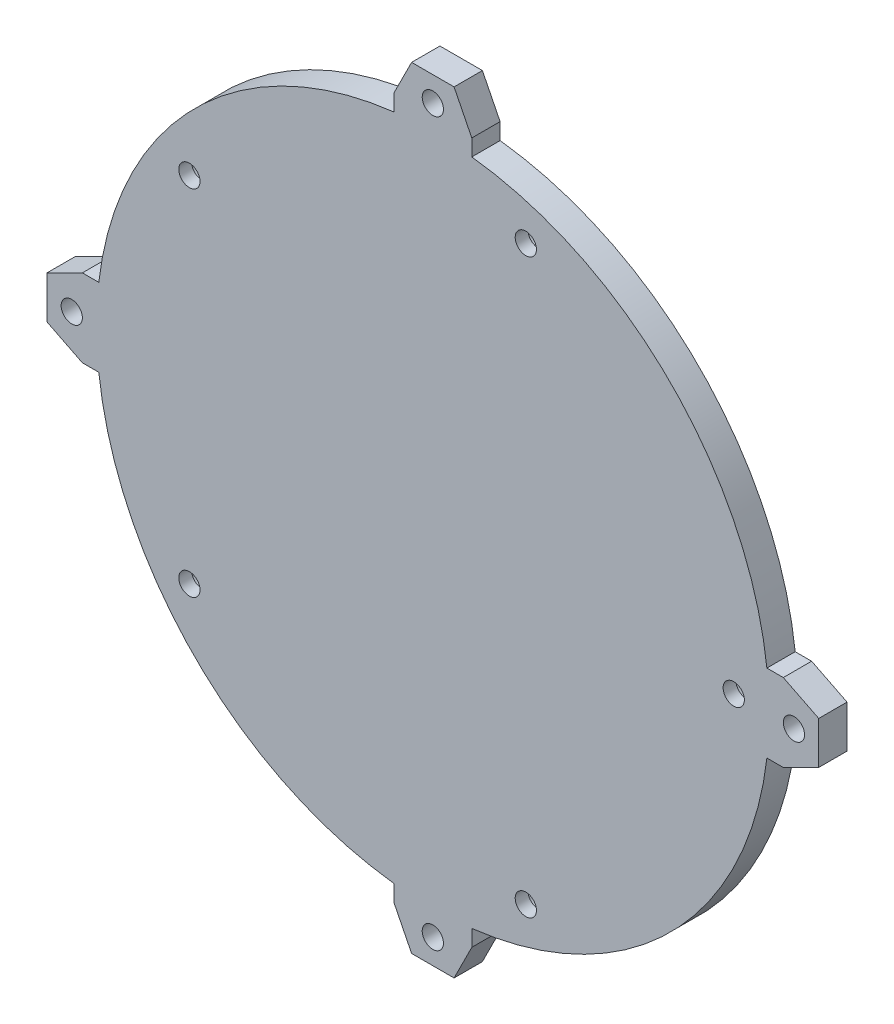
from build123d import *

# Parameters (mm, degrees)
SKETCH1_R           = 1.5
BOSS_EXTRUDE2_DEPTH = 4
SKETCH1_4_R         = 2.75
SKETCH1_4_R_2       = 1.5
CUT_EXTRUDE1_DEPTH  = 2.2


with BuildPart() as part:
    # Sketch1 → Boss-Extrude2 (new body)
    with BuildSketch(Plane.XY):
        with BuildLine():
            Line((57.5, 109), (51.5, 109))
            Line((51.5, 109), (49, 104))
            Line((49, 104), (49, 101.680504448))
            ThreePointArc((49, 101.680504448), (20.912427894, 88.087572106), (7.319495552, 60))
            Line((7.319495552, 60), (5, 60))
            Line((5, 60), (0, 57.5))
            Line((0, 57.5), (0, 51.5))
            Line((0, 51.5), (5, 49))
            Line((5, 49), (7.319495552, 49))
            ThreePointArc((7.319495552, 49), (20.912427894, 20.912427894), (49, 7.319495552))
            Line((49, 7.319495552), (49, 5))
            Line((49, 5), (51.5, 0))
            Line((51.5, 0), (57.5, 0))
            Line((57.5, 0), (60, 5))
            Line((60, 5), (60, 7.319495552))
            ThreePointArc((60, 7.319495552), (88.087572106, 20.912427894), (101.680504448, 49))
            Line((101.680504448, 49), (104, 49))
            Line((104, 49), (109, 51.5))
            Line((109, 51.5), (109, 57.5))
            Line((109, 57.5), (104, 60))
            Line((104, 60), (101.680504448, 60))
            ThreePointArc((101.680504448, 60), (88.087572106, 88.087572106), (60, 101.680504448))
            Line((60, 101.680504448), (60, 104))
            Line((60, 104), (57.5, 109))
        make_face()
        with Locations((54.5, 3.5)):
            Circle(SKETCH1_R, mode=Mode.SUBTRACT)
        with Locations((3.5, 54.5)):
            Circle(SKETCH1_R, mode=Mode.SUBTRACT)
        with Locations((105.5, 54.5)):
            Circle(SKETCH1_R, mode=Mode.SUBTRACT)
        with Locations((54.5, 105.5)):
            Circle(SKETCH1_R, mode=Mode.SUBTRACT)
        with Locations((20.116777739, 29.519126778)):
            Circle(SKETCH1_R, mode=Mode.SUBTRACT)
        with Locations((67.633222261, 14.080098057)):
            Circle(SKETCH1_R, mode=Mode.SUBTRACT)
        with Locations((20.116777739, 79.480873222)):
            Circle(SKETCH1_R, mode=Mode.SUBTRACT)
        with Locations((97, 54.5)):
            Circle(SKETCH1_R, mode=Mode.SUBTRACT)
        with Locations((67.633222261, 94.919901943)):
            Circle(SKETCH1_R, mode=Mode.SUBTRACT)
    extrude(amount=BOSS_EXTRUDE2_DEPTH)

    # Sketch1_4 → Cut-Extrude1 (cut)
    # profile 1 of 5: a face of its own
    with BuildSketch(Plane.XY):
        with Locations((20.116777739, 79.480873222)):
            Circle(SKETCH1_4_R)
        with Locations((20.116777739, 79.480873222)):
            Circle(SKETCH1_4_R_2, mode=Mode.SUBTRACT)
    # profile 2 of 5: a face of its own
    with BuildSketch(Plane.XY):
        with Locations((20.116777739, 29.519126778)):
            Circle(SKETCH1_4_R)
        with Locations((20.116777739, 29.519126778)):
            Circle(SKETCH1_4_R_2, mode=Mode.SUBTRACT)
    # profile 3 of 5: a face of its own
    with BuildSketch(Plane.XY):
        with Locations((67.633222261, 94.919901943)):
            Circle(SKETCH1_4_R)
        with Locations((67.633222261, 94.919901943)):
            Circle(SKETCH1_4_R_2, mode=Mode.SUBTRACT)
    # profile 4 of 5: a face of its own
    with BuildSketch(Plane.XY):
        with Locations((97, 54.5)):
            Circle(SKETCH1_4_R)
        with Locations((97, 54.5)):
            Circle(SKETCH1_4_R_2, mode=Mode.SUBTRACT)
    # profile 5 of 5: a face of its own
    with BuildSketch(Plane.XY):
        with Locations((67.633222261, 14.080098057)):
            Circle(SKETCH1_4_R)
        with Locations((67.633222261, 14.080098057)):
            Circle(SKETCH1_4_R_2, mode=Mode.SUBTRACT)
    extrude(amount=CUT_EXTRUDE1_DEPTH, mode=Mode.SUBTRACT)


solid = part.part
